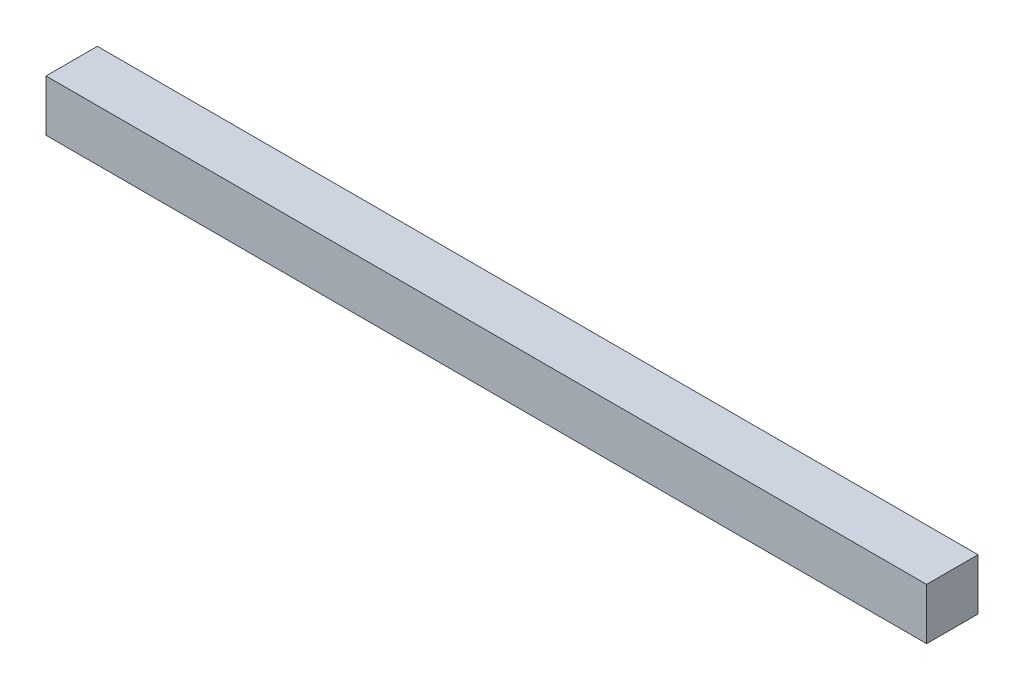
from build123d import *

# Parameters (mm, degrees)
BOSS_EXTRUDE1_DEPTH      = 381
BOSS_EXTRUDE1_DEPTH_BACK = 381
SKETCH1_W                = 44.45
SKETCH1_H                = 44.45


with BuildPart() as part:
    # Sketch1 → Boss-Extrude1 (new, two sides: drawn at the far end of the back side and taken through both)
    with BuildSketch(Plane(origin=(0, 0, 0), x_dir=(0, 0, -1), z_dir=(1, 0, 0)).offset(-BOSS_EXTRUDE1_DEPTH_BACK)):
        Rectangle(SKETCH1_W, SKETCH1_H)
    extrude(amount=BOSS_EXTRUDE1_DEPTH + BOSS_EXTRUDE1_DEPTH_BACK)


solid = part.part
